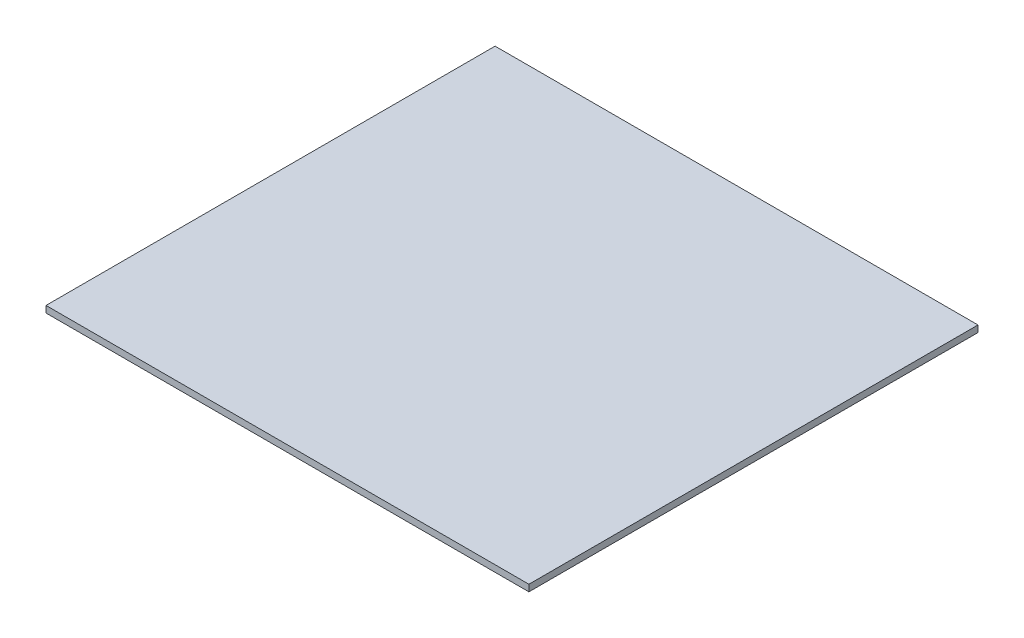
from build123d import *

# Parameters (mm, degrees)
SKETCH1_W           = 232.156
SKETCH1_H           = 215.9
BOSS_EXTRUDE1_DEPTH = 3.175


with BuildPart() as part:
    # Sketch1 → Boss-Extrude1 (new body)
    with BuildSketch(Plane(origin=(0, 0, 0), x_dir=(1, 0, 0), z_dir=(0, 1, 0))):
        with Locations((116.078, 107.95)):
            Rectangle(SKETCH1_W, SKETCH1_H)
    extrude(amount=BOSS_EXTRUDE1_DEPTH)


solid = part.part
